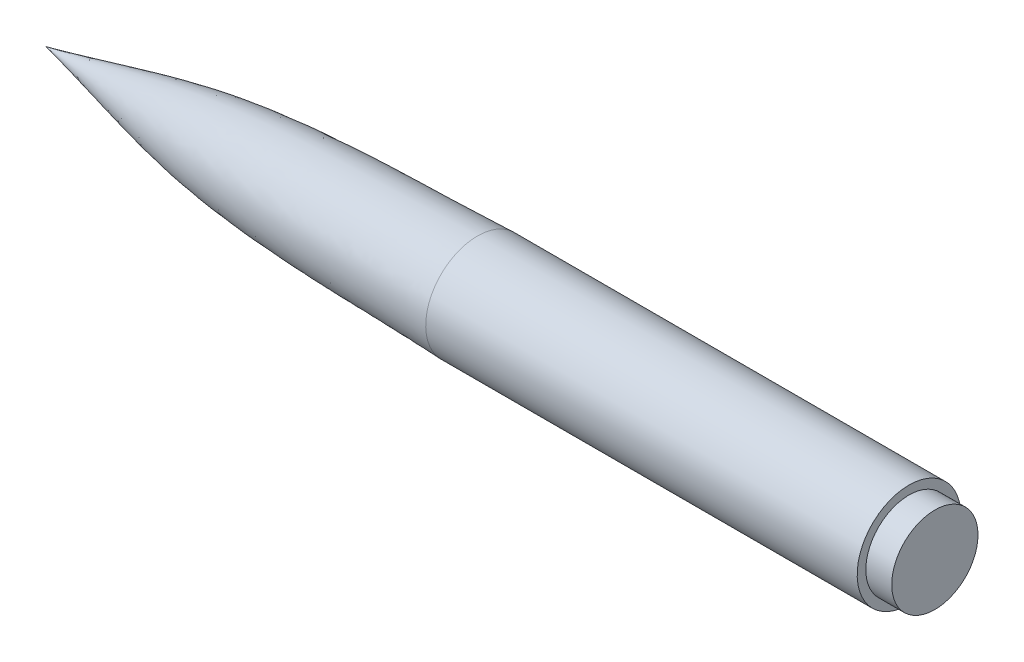
from build123d import *

# Parameters (mm, degrees)
SKETCH1_R           = 30
BOSS_EXTRUDE1_DEPTH = 250
SKETCH2_R           = 25
BOSS_EXTRUDE2_DEPTH = 15


with BuildPart() as part:
    # Sketch1 → Boss-Extrude1 (new body)
    with BuildSketch(Plane(origin=(0, 0, 0), x_dir=(0, 0, -1), z_dir=(1, 0, 0))):
        Circle(SKETCH1_R)
    extrude(amount=BOSS_EXTRUDE1_DEPTH)

    # Sketch2 → Boss-Extrude2 (add)
    with BuildSketch(Plane(origin=(250, 0, 0), x_dir=(0, 0, -1), z_dir=(1, 0, 0))):
        Circle(SKETCH2_R)
    extrude(amount=BOSS_EXTRUDE2_DEPTH)

    # Sketch3 → Revolve1 (revolve)
    with BuildSketch(Plane.XY):
        with BuildLine():
            Line((0, 30), (0, 0))
            Line((0, 0), (-250, 0))
            add(Edge.make_bspline(
                [(-250, 0), (-221.595628815, 6.156403899), (-140.370037823, 29.832530631), (-54.498709962, 27.773824359), (0, 30)],
                knots=[0, 0, 0, 0, 0.345336629, 1, 1, 1, 1], degree=3))
        make_face()
    revolve(axis=Axis((0, 0, 0), (-1, 0, 0)))


solid = part.part
